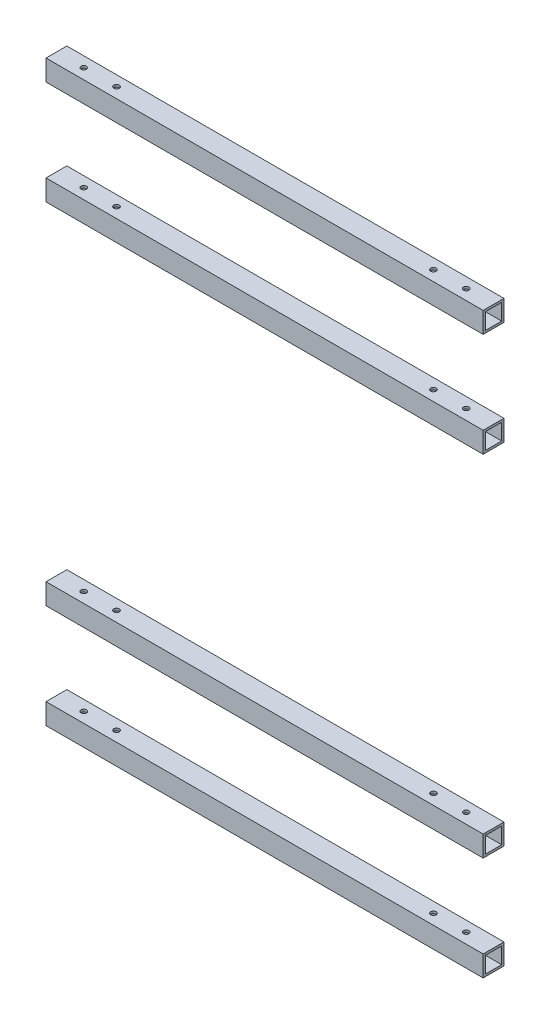
from build123d import *

# Parameters (mm, degrees)
SKETCH11_W                                    = 19.05
SKETCH11_H                                    = 19.05
SKETCH11_W_2                                  = 14.8336
SKETCH11_H_2                                  = 14.8336
AL_TUBE_SQUARE_AL_TUBE_0_75_SQR_X_0_083_DEPTH = 400
SKETCH11_ON_SEGMENT_2_W                       = 19.05
SKETCH11_ON_SEGMENT_2_H                       = 19.05
SKETCH11_ON_SEGMENT_2_W_2                     = 14.8336
SKETCH11_ON_SEGMENT_2_H_2                     = 14.8336
AL_TUBE_SQUARE_AL_TUBE_0_75_SQR_X_0_2_DEPTH   = 400
SKETCH11_ON_SEGMENT_3_W                       = 19.05
SKETCH11_ON_SEGMENT_3_H                       = 19.05
SKETCH11_ON_SEGMENT_3_W_2                     = 14.8336
SKETCH11_ON_SEGMENT_3_H_2                     = 14.8336
AL_TUBE_SQUARE_AL_TUBE_0_75_SQR_X_0_3_DEPTH   = 400
SKETCH11_ON_SEGMENT_4_W                       = 19.05
SKETCH11_ON_SEGMENT_4_H                       = 19.05
SKETCH11_ON_SEGMENT_4_W_2                     = 14.8336
SKETCH11_ON_SEGMENT_4_H_2                     = 14.8336
AL_TUBE_SQUARE_AL_TUBE_0_75_SQR_X_0_4_DEPTH   = 400
SKETCH12_R                                    = 2.5
CUT_EXTRUDE1_DEPTH                            = 664.313370983
SKETCH13_R                                    = 2.5
CUT_EXTRUDE2_DEPTH                            = 339.05


with BuildPart() as part:
    # Sketch11 → Al tube square AL TUBE 0.75 SQR X 0.083 WALL(1) (new body)
    with BuildSketch(Plane(origin=(0, -415, 0), x_dir=(0, 1, 0), z_dir=(1, 0, 0))):
        Rectangle(SKETCH11_W, SKETCH11_H)
        Rectangle(SKETCH11_W_2, SKETCH11_H_2, mode=Mode.SUBTRACT)
    extrude(amount=AL_TUBE_SQUARE_AL_TUBE_0_75_SQR_X_0_083_DEPTH)


with BuildPart() as body_2:
    # Sketch11 on segment 2 (carried to segment 2) → Al tube square AL TUBE 0.75 SQR X 0. 2 (new body)
    with BuildSketch(Plane(origin=(0, -95, 0), x_dir=(0, 1, 0), z_dir=(1, 0, 0))):
        Rectangle(SKETCH11_ON_SEGMENT_2_W, SKETCH11_ON_SEGMENT_2_H)
        Rectangle(SKETCH11_ON_SEGMENT_2_W_2, SKETCH11_ON_SEGMENT_2_H_2, mode=Mode.SUBTRACT)
    extrude(amount=AL_TUBE_SQUARE_AL_TUBE_0_75_SQR_X_0_2_DEPTH)


with BuildPart() as body_3:
    # Sketch11 on segment 3 (carried to segment 3) → Al tube square AL TUBE 0.75 SQR X 0. 3 (new body)
    with BuildSketch(Plane(origin=(0, -510, 0), x_dir=(0, 1, 0), z_dir=(1, 0, 0))):
        Rectangle(SKETCH11_ON_SEGMENT_3_W, SKETCH11_ON_SEGMENT_3_H)
        Rectangle(SKETCH11_ON_SEGMENT_3_W_2, SKETCH11_ON_SEGMENT_3_H_2, mode=Mode.SUBTRACT)
    extrude(amount=AL_TUBE_SQUARE_AL_TUBE_0_75_SQR_X_0_3_DEPTH)


with BuildPart() as body_4:
    # Sketch11 on segment 4 (carried to segment 4) → Al tube square AL TUBE 0.75 SQR X 0. 4 (new body)
    with BuildSketch(Plane.YZ):
        Rectangle(SKETCH11_ON_SEGMENT_4_W, SKETCH11_ON_SEGMENT_4_H)
        Rectangle(SKETCH11_ON_SEGMENT_4_W_2, SKETCH11_ON_SEGMENT_4_H_2, mode=Mode.SUBTRACT)
    extrude(amount=AL_TUBE_SQUARE_AL_TUBE_0_75_SQR_X_0_4_DEPTH)


with BuildPart() as cut_extrude1_tool:
    # Sketch12 → Cut-Extrude1 (new, through all)
    with BuildSketch(Plane.XZ.offset(519.525)):
        with Locations(Location((25, 0, 0), (0, 0, 90))):
            Circle(SKETCH12_R)
        with Locations(Location((55, 0, 0), (0, 0, 90))):
            Circle(SKETCH12_R)
        with Locations(Location((345, 0, 0), (0, 0, 90))):
            Circle(SKETCH12_R)
        with Locations(Location((375, 0, 0), (0, 0, 90))):
            Circle(SKETCH12_R)
    extrude(amount=-CUT_EXTRUDE1_DEPTH)


with BuildPart() as body_3_1:
    add(body_3.part)

    # Cut-Extrude1: cut by cut_extrude1_tool
    add(cut_extrude1_tool.part, mode=Mode.SUBTRACT)


with BuildPart() as body_4_1:
    add(body_4.part)

    # Cut-Extrude1: cut by cut_extrude1_tool
    add(cut_extrude1_tool.part, mode=Mode.SUBTRACT)


with BuildPart() as cut_extrude2_tool:
    # Sketch13 → Cut-Extrude2 (new body)
    with BuildSketch(Plane.XZ.offset(424.525)):
        with Locations(Location((25, 0, 0), (0, 0, 90))):
            Circle(SKETCH13_R)
        with Locations(Location((55, 0, 0), (0, 0, 90))):
            Circle(SKETCH13_R)
        with Locations(Location((345, 0, 0), (0, 0, 90))):
            Circle(SKETCH13_R)
        with Locations(Location((375, 0, 0), (0, 0, 90))):
            Circle(SKETCH13_R)
    extrude(amount=-CUT_EXTRUDE2_DEPTH)


with BuildPart() as part_1:
    add(part.part)

    # Cut-Extrude2: cut by cut_extrude2_tool
    add(cut_extrude2_tool.part, mode=Mode.SUBTRACT)


with BuildPart() as body_2_1:
    add(body_2.part)

    # Cut-Extrude2: cut by cut_extrude2_tool
    add(cut_extrude2_tool.part, mode=Mode.SUBTRACT)


solid = Compound([body_3_1.part, body_4_1.part, part_1.part, body_2_1.part])
